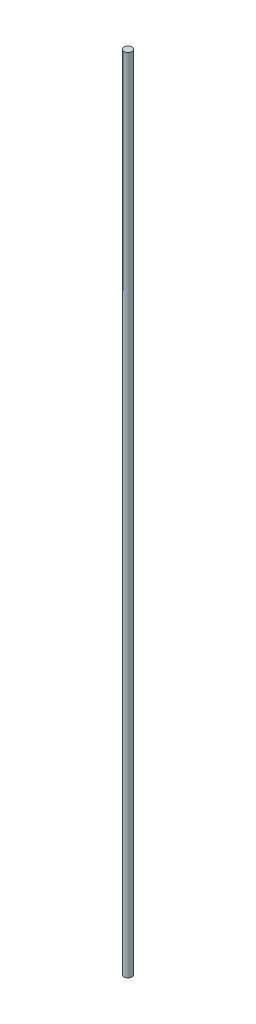
from build123d import *

# Parameters (mm, degrees)
ESQUISSE1_R        = 1.5
BOSS_EXTRU_1_DEPTH = 300


with BuildPart() as part:
    # Esquisse1 → Boss.-Extru.1 (new body)
    with BuildSketch(Plane(origin=(0, 0, 0), x_dir=(1, 0, 0), z_dir=(0, 1, 0))):
        Circle(ESQUISSE1_R)
    extrude(amount=BOSS_EXTRU_1_DEPTH)


solid = part.part
